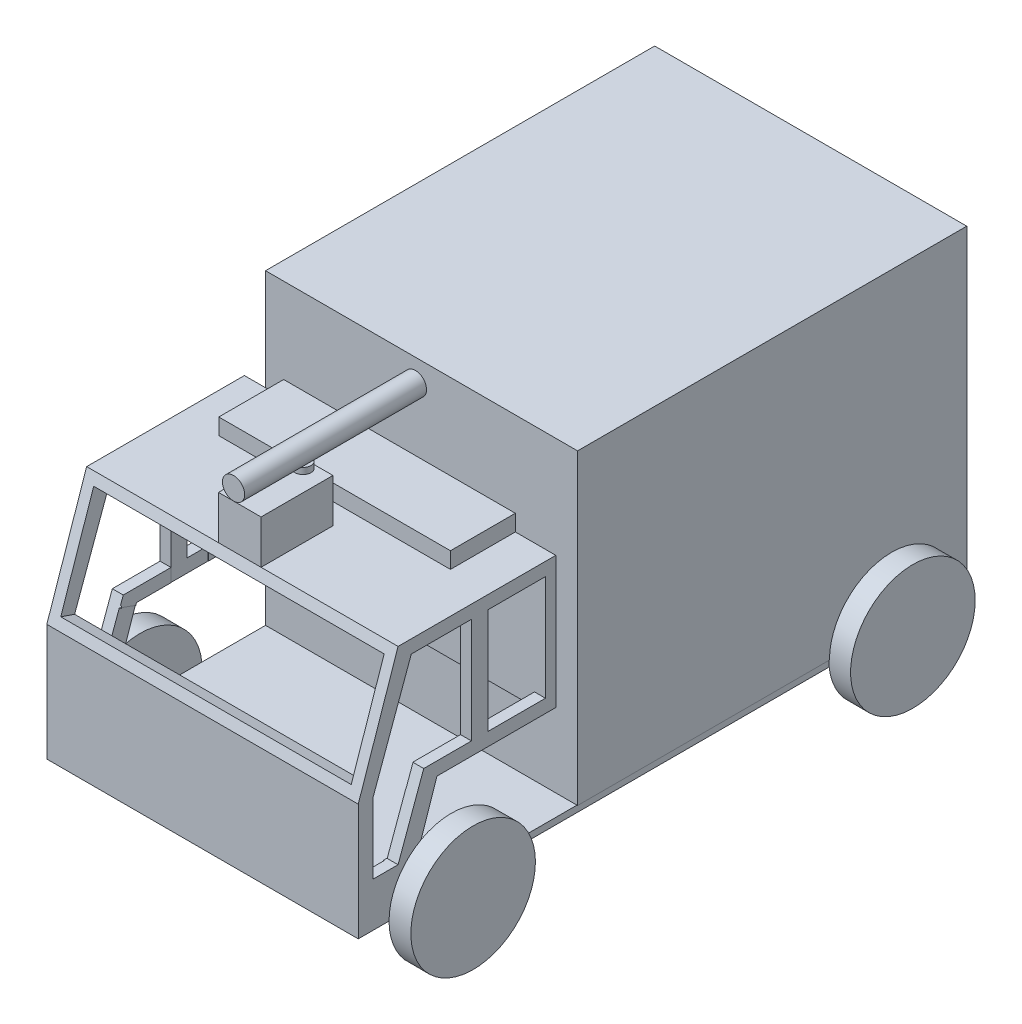
from build123d import *

# Parameters (mm, degrees)
IZIM2_W                           = 624.83438286
IZIM2_H                           = 493.118424104
Y_KSEKLIK_EKSTR_ZYON1_DEPTH       = 500
IZIM4_R                           = 100
Y_KSEKLIK_EKSTR_ZYON2_DEPTH       = 35
IZIM5_W                           = 975.967830922
IZIM5_H                           = 10.395315862
Y_KSEKLIK_EKSTR_ZYON3_DEPTH       = 500
IZIM6_W                           = 317.202351564
IZIM6_H                           = 374.704466417
Y_KSEKLIK_EKSTR_ZYON4_DEPTH       = 500
KES_EKSTR_ZYON1_DEPTH             = 500
KES_EKSTR_ZYON2_DEPTH             = 500
KES_EKSTR_ZYON3_DEPTH             = 500
IZIM11_R                          = 100
Y_KSEKLIK_EKSTR_ZYON5_DEPTH       = 35
IZIM12_W                          = 466.303391348
IZIM12_H                          = 163.89871841
KES_EKSTR_ZYON4_DEPTH             = 35
IZIM17_W                          = 464.870730912
IZIM17_H                          = 199.827267797
KES_EKSTR_ZYON7_DEPTH             = 35
IZIM20_W                          = 465.660425645
IZIM20_H                          = 104.591429086
KES_EKSTR_ZYON8_DEPTH             = 35
IZIM21_W                          = 463.56331291
IZIM21_H                          = 33.15833205
KES_EKSTR_ZYON9_DEPTH             = 35
IZIM22_W                          = 465.770217683
IZIM22_H                          = 55.70279957
KES_EKSTR_ZYON10_DEPTH            = 35
IZIM23_W                          = 466.303391348
IZIM23_H                          = 30.655819637
KES_EKSTR_ZYON11_DEPTH            = 60
IZIM25_W                          = 26.274086754
IZIM25_H                          = 211.571078613
Y_KSEKLIK_EKSTR_ZYON6_DEPTH       = 500
IZIM27_W                          = 465.215365456
IZIM27_H                          = 190.357875177
KES_EKSTR_ZYON12_DEPTH            = 60
IZIM28_R                          = 100
Y_KSEKLIK_EKSTR_ZYON7_DEPTH       = 35
IZIM46_W                          = 68.290210942
IZIM46_H                          = 115.402230531
Y_KSEKLIK_EKSTR_ZYON14_DEPTH      = 70
IZIM47_R                          = 12.712595137
Y_KSEKLIK_EKSTR_ZYON15_DEPTH      = 10
IZIM48_R                          = 17.808743389
Y_KSEKLIK_EKSTR_ZYON18_DEPTH      = 10
Y_KSEKLIK_EKSTR_ZYON18_DEPTH_BACK = 282
IZIM49_W                          = 371.925281581
IZIM49_H                          = 104.164908848
Y_KSEKLIK_EKSTR_ZYON19_DEPTH      = 26
IZIM54_W                          = 624.83438286
IZIM54_H                          = 493.118424104
Y_KSEKLIK_EKSTR_ZYON20_DEPTH      = 1


with BuildPart() as part:
    # Çizim2 → Yükseklik-Ekstrüzyon1 (new body)
    with BuildSketch(Plane(origin=(0, 0, 0), x_dir=(0, 0, -1), z_dir=(1, 0, 0))):
        with Locations((945.419542605, 684.894087956)):
            Rectangle(IZIM2_W, IZIM2_H)
    extrude(amount=-Y_KSEKLIK_EKSTR_ZYON1_DEPTH)

    # Çizim4 → Yükseklik-Ekstrüzyon2 (add)
    with BuildSketch(Plane(origin=(0, 0, 0), x_dir=(0, 0, -1), z_dir=(1, 0, 0))):
        with Locations((1137.354295612, 438.334875904)):
            Circle(IZIM4_R)
    extrude(amount=Y_KSEKLIK_EKSTR_ZYON2_DEPTH)

    # Çizim5 → Yükseklik-Ekstrüzyon3 (add)
    with BuildSketch(Plane(origin=(0, 0, 0), x_dir=(0, 0, -1), z_dir=(1, 0, 0))):
        with Locations((769.852818574, 433.137217973)):
            Rectangle(IZIM5_W, IZIM5_H)
    extrude(amount=-Y_KSEKLIK_EKSTR_ZYON3_DEPTH)

    # Çizim6 → Yükseklik-Ekstrüzyon4 (add)
    with BuildSketch(Plane(origin=(0, 0, 0), x_dir=(0, 0, -1), z_dir=(1, 0, 0))):
        with Locations((440.470078895, 615.291793251)):
            Rectangle(IZIM6_W, IZIM6_H)
    extrude(amount=-Y_KSEKLIK_EKSTR_ZYON4_DEPTH)

    # Çizim7 → Kes-Ekstrüzyon1 (cut)
    with BuildSketch(Plane(origin=(0, 0, 0), x_dir=(0, 0, -1), z_dir=(1, 0, 0))):
        Polygon((281.868903113, 802.644026459), (345.819234143, 802.644026459), (281.868903113, 615.29179325), align=None)
    extrude(amount=-KES_EKSTR_ZYON1_DEPTH, mode=Mode.SUBTRACT)

    # Çizim8 → Kes-Ekstrüzyon2 (cut)
    with BuildSketch(Plane(origin=(0, 0, 0), x_dir=(0, 0, -1), z_dir=(1, 0, 0))):
        Polygon((367.032437579, 781.430823023), (305.46881178, 612.286151281), (305.46881178, 499.123252309), (345.819234143, 499.123252309), (387.007160993, 612.286151281), (582.392266599, 612.286151281), (582.392266599, 781.430823023), align=None)
    extrude(amount=-KES_EKSTR_ZYON2_DEPTH, mode=Mode.SUBTRACT)

    # Çizim10 → Kes-Ekstrüzyon3 (cut)
    with BuildSketch(Plane(origin=(0, 0, 0), x_dir=(0, 0, -1), z_dir=(1, 0, 0))):
        Polygon((599.071254677, 438.334875904), (356.541223106, 438.334875904), (408.220364428, 591.072947846), (599.071254677, 591.072947846), align=None)
    extrude(amount=-KES_EKSTR_ZYON3_DEPTH, mode=Mode.SUBTRACT)

    # Çizim11 → Yükseklik-Ekstrüzyon5 (add)
    with BuildSketch(Plane(origin=(0, 0, 0), x_dir=(0, 0, -1), z_dir=(1, 0, 0))):
        with Locations((431.321316174, 427.939560042)):
            Circle(IZIM11_R)
    extrude(amount=Y_KSEKLIK_EKSTR_ZYON5_DEPTH)

    # Çizim12 → Kes-Ekstrüzyon4 (cut)
    with BuildSketch(Plane(origin=(0, -21.964844226, -64.349355999), x_dir=(1, 0, 0), z_dir=(0, 0.323037077, 0.94638631))):
        with Locations((-250, 772.34079435)):
            Rectangle(IZIM12_W, IZIM12_H)
    extrude(amount=-KES_EKSTR_ZYON4_DEPTH, mode=Mode.SUBTRACT)

    # Çizim17 → Kes-Ekstrüzyon7 (cut)
    with BuildSketch(Plane(origin=(0, 612.286151281, 0), x_dir=(1, 0, 0), z_dir=(0, 1, 0))):
        with Locations((-250, 482.478632701)):
            Rectangle(IZIM17_W, IZIM17_H)
    extrude(amount=-KES_EKSTR_ZYON7_DEPTH, mode=Mode.SUBTRACT)

    # Çizim20 → Kes-Ekstrüzyon8 (cut)
    with BuildSketch(Plane(origin=(0, -52.757830226, -144.950947246), x_dir=(1, 0, 0), z_dir=(0, 0.342020143, 0.939692621))):
        with Locations((-250.321482852, 639.324434245)):
            Rectangle(IZIM20_W, IZIM20_H)
    extrude(amount=-KES_EKSTR_ZYON8_DEPTH, mode=Mode.SUBTRACT)

    # Çizim21 → Kes-Ekstrüzyon9 (cut)
    with BuildSketch(Plane(origin=(0, -52.757830226, -144.950947246), x_dir=(1, 0, 0), z_dir=(0, 0.342020143, 0.939692621))):
        with Locations((-249.003107825, 691.169166414)):
            Rectangle(IZIM21_W, IZIM21_H)
    extrude(amount=-KES_EKSTR_ZYON9_DEPTH, mode=Mode.SUBTRACT)

    # Çizim22 → Kes-Ekstrüzyon10 (cut)
    with BuildSketch(Plane(origin=(0, -63.217651249, -186.84022059), x_dir=(-1, 0, 0), z_dir=(0, -0.320502572, -0.947247645))):
        with Locations((250.835570057, 555.815526561)):
            Rectangle(IZIM22_W, IZIM22_H)
    extrude(amount=-KES_EKSTR_ZYON10_DEPTH, mode=Mode.SUBTRACT)

    # Çizim23 → Kes-Ekstrüzyon11 (cut)
    with BuildSketch(Plane(origin=(0, 499.123252309, 0), x_dir=(1, 0, 0), z_dir=(0, 1, 0))):
        with Locations((-250, 324.988840267)):
            Rectangle(IZIM23_W, IZIM23_H)
    extrude(amount=-KES_EKSTR_ZYON11_DEPTH, mode=Mode.SUBTRACT)

    # Çizim25 → Yükseklik-Ekstrüzyon6 (add)
    with BuildSketch(Plane(origin=(0, 0, 0), x_dir=(0, 0, -1), z_dir=(1, 0, 0))):
        with Locations((476.795697093, 696.858487153)):
            Rectangle(IZIM25_W, IZIM25_H)
    extrude(amount=-Y_KSEKLIK_EKSTR_ZYON6_DEPTH)

    # Çizim27 → Kes-Ekstrüzyon12 (cut)
    with BuildSketch(Plane.XY.offset(-463.658653716)):
        with Locations((-250.172317272, 686.251885435)):
            Rectangle(IZIM27_W, IZIM27_H)
    extrude(amount=-KES_EKSTR_ZYON12_DEPTH, mode=Mode.SUBTRACT)

    # Çizim28 → Yükseklik-Ekstrüzyon7 (add)
    with BuildSketch(Plane.ZY.offset(500)):
        with Locations((-431.321316174, 427.939560042)):
            Circle(IZIM28_R)
        with Locations((-1135.713642363, 438.334875904)):
            Circle(IZIM28_R)
    extrude(amount=Y_KSEKLIK_EKSTR_ZYON7_DEPTH)

    # Çizim46 → Yükseklik-Ekstrüzyon14 (add)
    with BuildSketch(Plane(origin=(0, 802.644026459, 0), x_dir=(1, 0, 0), z_dir=(0, 1, 0))):
        with Locations((-254.145105471, 403.520349409)):
            Rectangle(IZIM46_W, IZIM46_H)
    extrude(amount=Y_KSEKLIK_EKSTR_ZYON14_DEPTH)

    # Çizim47 → Yükseklik-Ekstrüzyon15 (add)
    with BuildSketch(Plane(origin=(0, 872.644026459, 0), x_dir=(1, 0, 0), z_dir=(0, 1, 0))):
        with Locations((-254.145105471, 447.358410318)):
            Circle(IZIM47_R)
    extrude(amount=Y_KSEKLIK_EKSTR_ZYON15_DEPTH)

    # Çizim49 → Yükseklik-Ekstrüzyon19 (add)
    with BuildSketch(Plane(origin=(0, 802.644026459, 0), x_dir=(1, 0, 0), z_dir=(0, 1, 0))):
        with Locations((-250.97344325, 546.988800253)):
            Rectangle(IZIM49_W, IZIM49_H)
    extrude(amount=Y_KSEKLIK_EKSTR_ZYON19_DEPTH)

    # Çizim54 → Yükseklik-Ekstrüzyon20 (add)
    with BuildSketch(Plane(origin=(0, 0, 0), x_dir=(0, 0, -1), z_dir=(1, 0, 0))):
        with Locations((945.419542605, 684.894087956)):
            Rectangle(IZIM54_W, IZIM54_H)
    extrude(amount=Y_KSEKLIK_EKSTR_ZYON20_DEPTH)


with BuildPart() as body_2:
    # Çizim48 → Yükseklik-Ekstrüzyon18 (new body, two sides)
    with BuildSketch(Plane.XY.offset(-345.819234143)) as y_kseklik_ekstr_zyon18_sk:
        with Locations((-254.145105471, 900.452769847)):
            Circle(IZIM48_R)
    extrude(amount=Y_KSEKLIK_EKSTR_ZYON18_DEPTH)
    extrude(y_kseklik_ekstr_zyon18_sk.sketch, amount=-Y_KSEKLIK_EKSTR_ZYON18_DEPTH_BACK)


solid = Compound([part.part, body_2.part])
